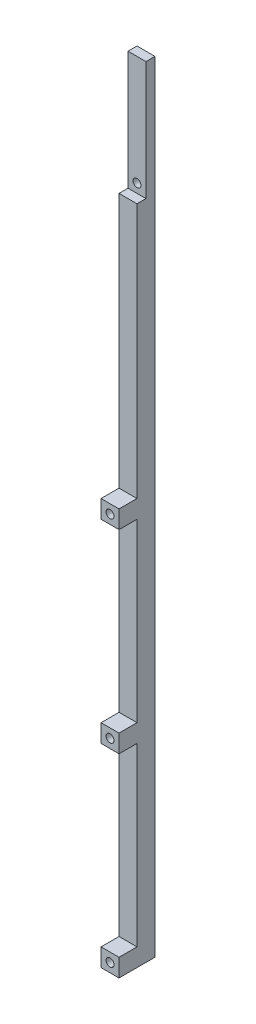
from build123d import *

# Parameters (mm, degrees)
SKETCH1_W                  = 6.35
SKETCH1_H                  = 12.7
BOSS_EXTRUDE1_DEPTH        = 275.59
CUT_EXTRUDE_THIN1_DEPTH    = 276.955540984
F_35_0_11_DIAMETER_HOLE1_D = 2.794


with BuildPart() as part:
    # Sketch1 → Boss-Extrude1 (new body)
    with BuildSketch(Plane(origin=(0, 0, 0), x_dir=(1, 0, 0), z_dir=(0, 1, 0))):
        with Locations((3.175, 6.35)):
            Rectangle(SKETCH1_W, SKETCH1_H)
    extrude(amount=BOSS_EXTRUDE1_DEPTH)

    # Sketch2 → Cut-Extrude-Thin1 (cut, through all)
    with BuildSketch(Plane.ZY):
        Polygon((0, 233.68), (-9.525, 233.68), (-9.525, 275.59), (-9.52510033, 275.59), (-9.52510033, 233.67989967), (0, 233.67989967), align=None)
        Polygon((0, 143.51), (-6.35, 143.51), (-6.35, 233.68), (-6.35010033, 233.68), (-6.35010033, 143.50989967), (0, 143.50989967), align=None)
        Polygon((0, 137.16), (-6.35, 137.16), (-6.35, 74.93), (0, 74.93), (0, 74.93010033), (-6.34989967, 74.93010033), (-6.34989967, 137.15989967), (0, 137.15989967), align=None)
        Polygon((0, 68.58), (-6.35, 68.58), (-6.35, 6.35), (0, 6.35), (0, 6.35010033), (-6.34989967, 6.35010033), (-6.34989967, 68.57989967), (0, 68.57989967), align=None)
    extrude(amount=-CUT_EXTRUDE_THIN1_DEPTH, mode=Mode.SUBTRACT)


with BuildPart() as cut_extrude_thin1_kept_piece:
    # of the separate pieces the step leaves, the one the design keeps (cut_extrude_thin1_pieces_kept)
    add(part.part.solids().sort_by_distance((0, 0, 0))[0])

    # #35 (0.11) Diameter Hole1 (through all)
    with Locations(Plane.XY):
        with Locations((3.175, 236.855), (3.175, 140.335), (3.175, 71.755), (3.175, 3.175)):
            Hole(F_35_0_11_DIAMETER_HOLE1_D / 2)


solid = cut_extrude_thin1_kept_piece.part
